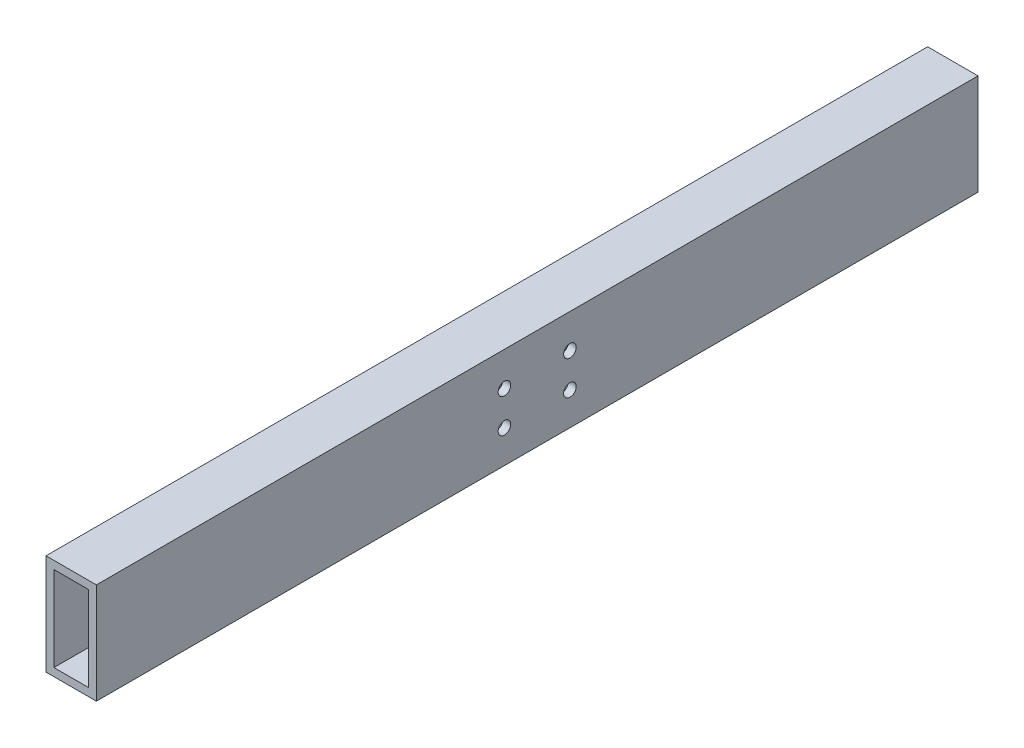
from build123d import *

# Parameters (mm, degrees)
SKETCH1_W            = 40
SKETCH1_H            = 80
SKETCH1_W_2          = 27.4
SKETCH1_H_2          = 67.4
M8_CLEARANCE_HOLE1_D = 10


with BuildPart() as part:
    # Sweep1: sweep along a curve in space
    with BuildLine() as sweep1_path:
        add(Edge.make_bspline(
            [(0, 0, -350), (0, 0, 350)],
            knots=[0, 0, 1, 1], degree=1))
    # Sketch1 → Sweep1 (sweep)
    with BuildSketch(Plane.XY):
        Rectangle(SKETCH1_W, SKETCH1_H)
        Rectangle(SKETCH1_W_2, SKETCH1_H_2, mode=Mode.SUBTRACT)
    sweep(path=sweep1_path.line)

    # M8 Clearance Hole1 (through all)
    with Locations(Plane(origin=(20, 0, 0), x_dir=(0, 0, -1), z_dir=(1, 0, 0))):
        with Locations((26, 13), (26, -14)):
            m8_clearance_hole1 = Hole(M8_CLEARANCE_HOLE1_D / 2)

    # Mirror1: M8 Clearance Hole1 across plane
    add(m8_clearance_hole1.mirror(Plane.XY), mode=Mode.SUBTRACT)


solid = part.part
